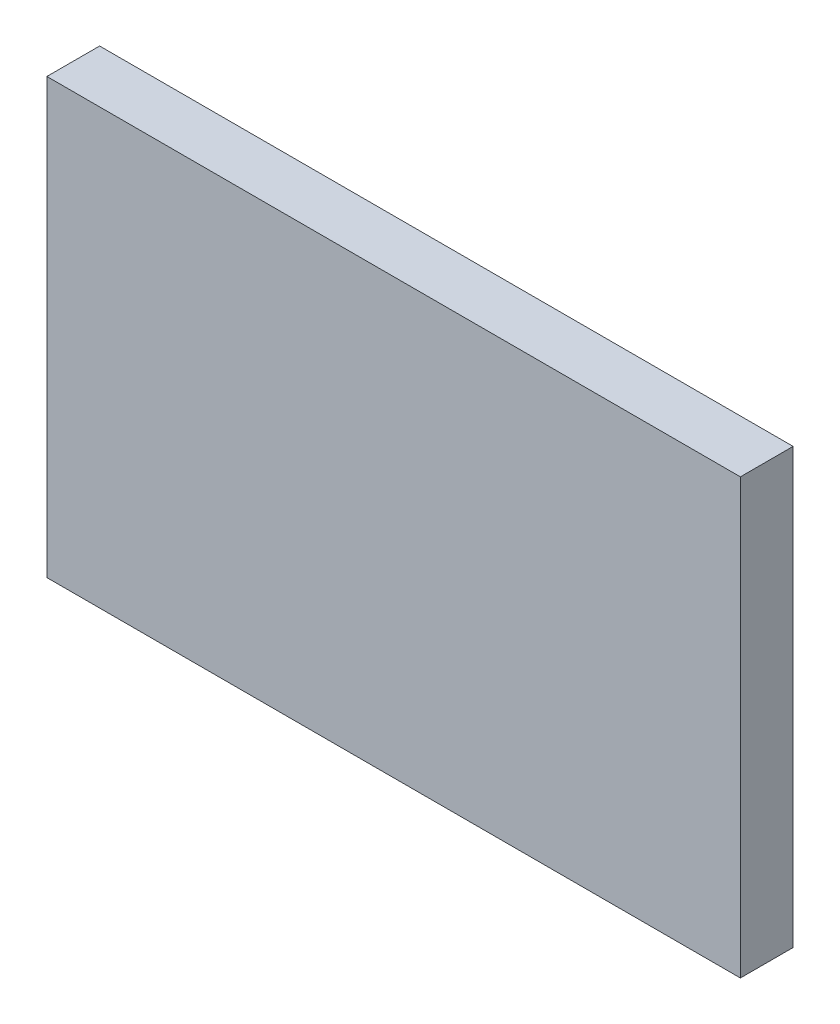
from build123d import *

# Parameters (mm, degrees)
SKETCH1_W           = 65.75
SKETCH1_H           = 5
BOSS_EXTRUDE1_DEPTH = 41.15


with BuildPart() as part:
    # Sketch1 → Boss-Extrude1 (new body)
    with BuildSketch(Plane(origin=(0, 0, 0), x_dir=(1, 0, 0), z_dir=(0, 1, 0))):
        Rectangle(SKETCH1_W, SKETCH1_H)
    extrude(amount=BOSS_EXTRUDE1_DEPTH)


solid = part.part
